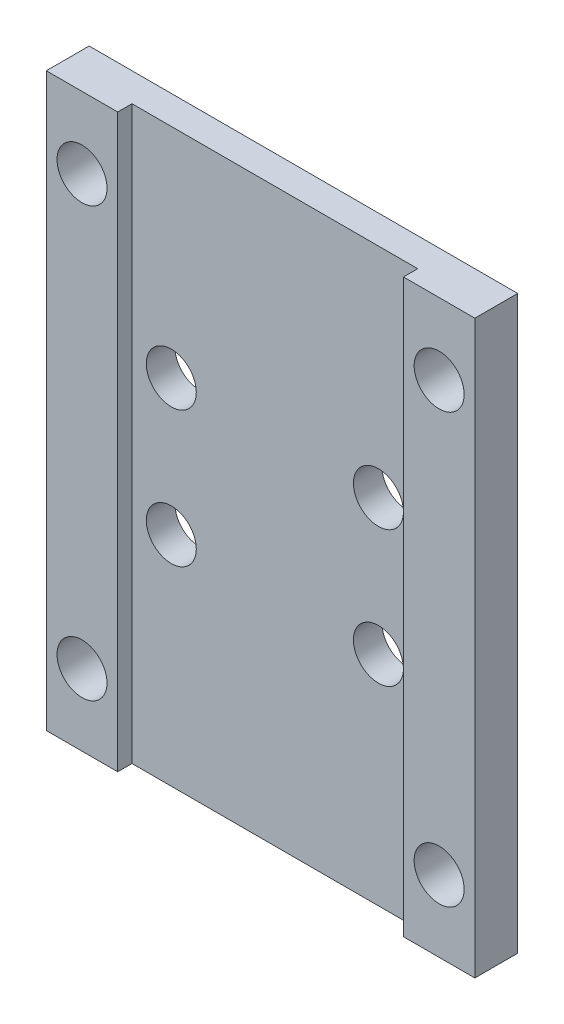
from build123d import *

# Parameters (mm, degrees)
ESQUISSE1_W        = 30
ESQUISSE1_H        = 40
ESQUISSE1_R        = 1.75
BOSS_EXTRU_1_DEPTH = 2
BOSS_EXTRU_2_START = 1
ESQUISSE1_3_W      = 5
ESQUISSE1_3_H      = 40
ESQUISSE1_3_R      = 1.75
BOSS_EXTRU_2_DEPTH = 1


with BuildPart() as part:
    # Esquisse1 → Boss.-Extru.1 (new body)
    with BuildSketch(Plane.XY):
        Rectangle(ESQUISSE1_W, ESQUISSE1_H)
        with Locations((-7.25, -4.75)):
            Circle(ESQUISSE1_R, mode=Mode.SUBTRACT)
        with Locations((7.25, -4.75)):
            Circle(ESQUISSE1_R, mode=Mode.SUBTRACT)
        with Locations((-7.25, 4.75)):
            Circle(ESQUISSE1_R, mode=Mode.SUBTRACT)
        with Locations((7.25, 4.75)):
            Circle(ESQUISSE1_R, mode=Mode.SUBTRACT)
        with Locations((12.5, 15)):
            Circle(ESQUISSE1_R, mode=Mode.SUBTRACT)
        with Locations((12.5, -15)):
            Circle(ESQUISSE1_R, mode=Mode.SUBTRACT)
        with Locations((-12.5, 15)):
            Circle(ESQUISSE1_R, mode=Mode.SUBTRACT)
        with Locations((-12.5, -15)):
            Circle(ESQUISSE1_R, mode=Mode.SUBTRACT)
    extrude(amount=-BOSS_EXTRU_1_DEPTH)

    # Esquisse1_3 → Boss.-Extru.2 (add)
    # profile 1 of 2: a face of its own
    with BuildSketch(Plane.XY.offset(BOSS_EXTRU_2_START)):
        with Locations((-12.5, 0)):
            Rectangle(ESQUISSE1_3_W, ESQUISSE1_3_H)
        with Locations((-12.5, -15)):
            Circle(ESQUISSE1_3_R, mode=Mode.SUBTRACT)
        with Locations((-12.5, 15)):
            Circle(ESQUISSE1_3_R, mode=Mode.SUBTRACT)
    # profile 2 of 2: a face of its own
    with BuildSketch(Plane.XY.offset(BOSS_EXTRU_2_START)):
        with Locations((12.5, 0)):
            Rectangle(ESQUISSE1_3_W, ESQUISSE1_3_H)
        with Locations((12.5, -15)):
            Circle(ESQUISSE1_3_R, mode=Mode.SUBTRACT)
        with Locations((12.5, 15)):
            Circle(ESQUISSE1_3_R, mode=Mode.SUBTRACT)
    extrude(amount=-BOSS_EXTRU_2_DEPTH)


solid = part.part
